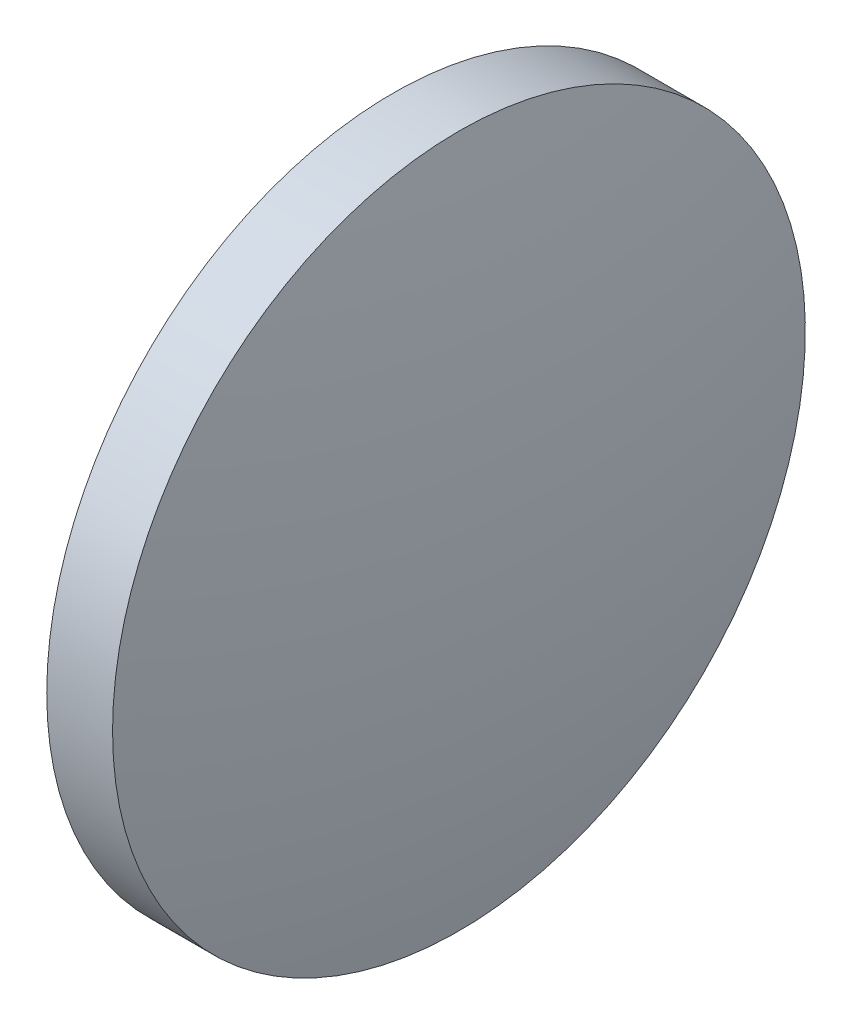
from build123d import *


with BuildPart() as part:
    # 草图2 → 旋转1 (revolve)
    with BuildSketch(Plane.XY):
        with BuildLine():
            Line((408.167492842, 111.079788522), (408.167492842, 119.079788522))
            Line((408.167492842, 119.079788522), (409.687492842, 119.079788522))
            ThreePointArc((409.687492842, 119.079788522), (410.272031602, 115.098756051), (410.467492842, 111.079788522))
            Line((410.467492842, 111.079788522), (408.167492842, 111.079788522))
        make_face()
    revolve(axis=Axis((404.442224222, 111.079788522, 0), (1, 0, 0)))


solid = part.part
